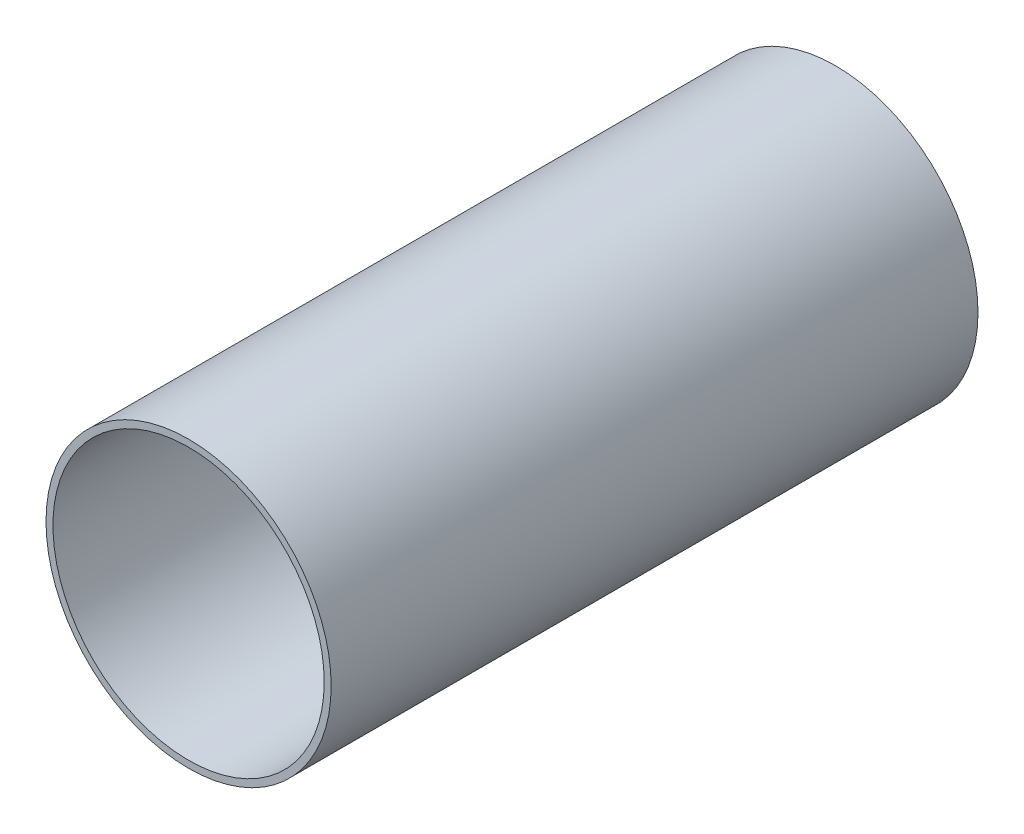
from build123d import *

# Parameters (mm, degrees)
SKETCH1_R           = 20.5
BOSS_EXTRUDE1_DEPTH = 93
SKETCH2_R           = 19.5
CUT_EXTRUDE1_DEPTH  = 94


with BuildPart() as part:
    # Sketch1 → Boss-Extrude1 (new body)
    with BuildSketch(Plane.XY):
        Circle(SKETCH1_R)
    extrude(amount=BOSS_EXTRUDE1_DEPTH)

    # Sketch2 → Cut-Extrude1 (cut, through all)
    with BuildSketch(Plane.XY.offset(93)):
        Circle(SKETCH2_R)
    extrude(amount=-CUT_EXTRUDE1_DEPTH, mode=Mode.SUBTRACT)


solid = part.part
